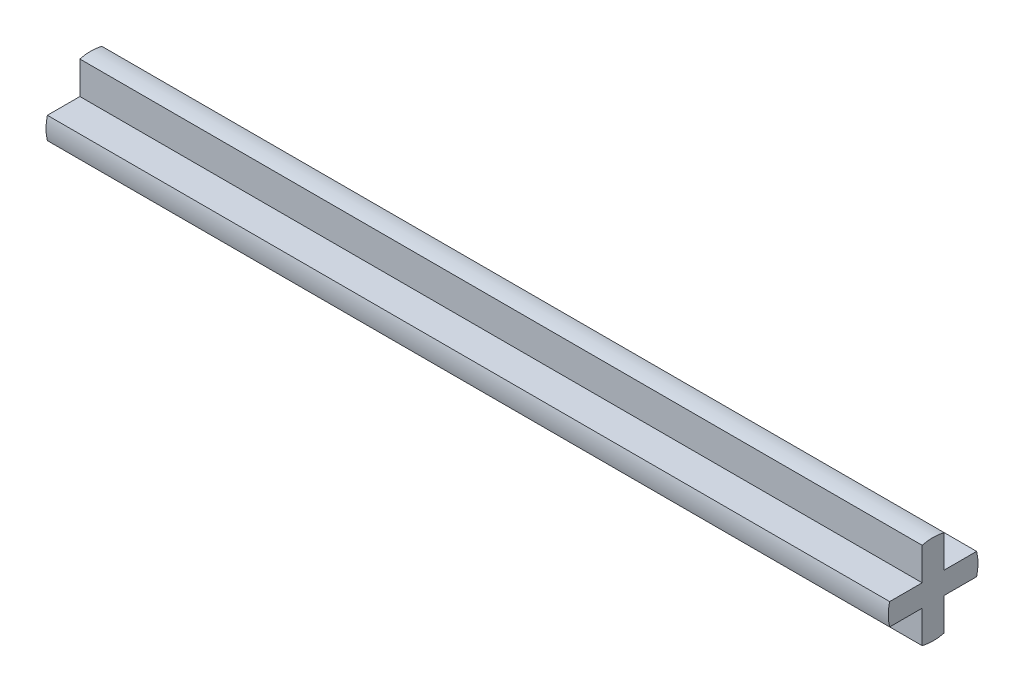
from build123d import *

# Parameters (mm, degrees)
SKETCH_1_R          = 2.45
EXTRUDE_1_DEPTH     = 23
SKETCH_2_OUTSIDE_W  = 16.204
SKETCH_2_OUTSIDE_H  = 16.204
CUT_EXTRUDE_1_DEPTH = 47


with BuildPart() as part:
    # 草图1 → 凸台-拉伸1 (new body, symmetric)
    with BuildSketch(Plane(origin=(0, 0, 0), x_dir=(0, 0, -1), z_dir=(1, 0, 0))):
        Circle(SKETCH_1_R)
    extrude(amount=EXTRUDE_1_DEPTH, both=True)

    # 草图2 outside → 切除-拉伸1 (cut, through all)
    with BuildSketch(Plane(origin=(23, 0, 0), x_dir=(0, 0, -1), z_dir=(1, 0, 0))):
        Rectangle(SKETCH_2_OUTSIDE_W, SKETCH_2_OUTSIDE_H)
        Polygon((-3, 0.6), (-0.6, 0.6), (-0.6, 3), (0.6, 3), (0.6, 0.6), (3, 0.6), (3, -0.6), (0.6, -0.6), (0.6, -3), (-0.6, -3), (-0.6, -0.6), (-3, -0.6), align=None, mode=Mode.SUBTRACT)
    extrude(amount=-CUT_EXTRUDE_1_DEPTH, mode=Mode.SUBTRACT)


solid = part.part
